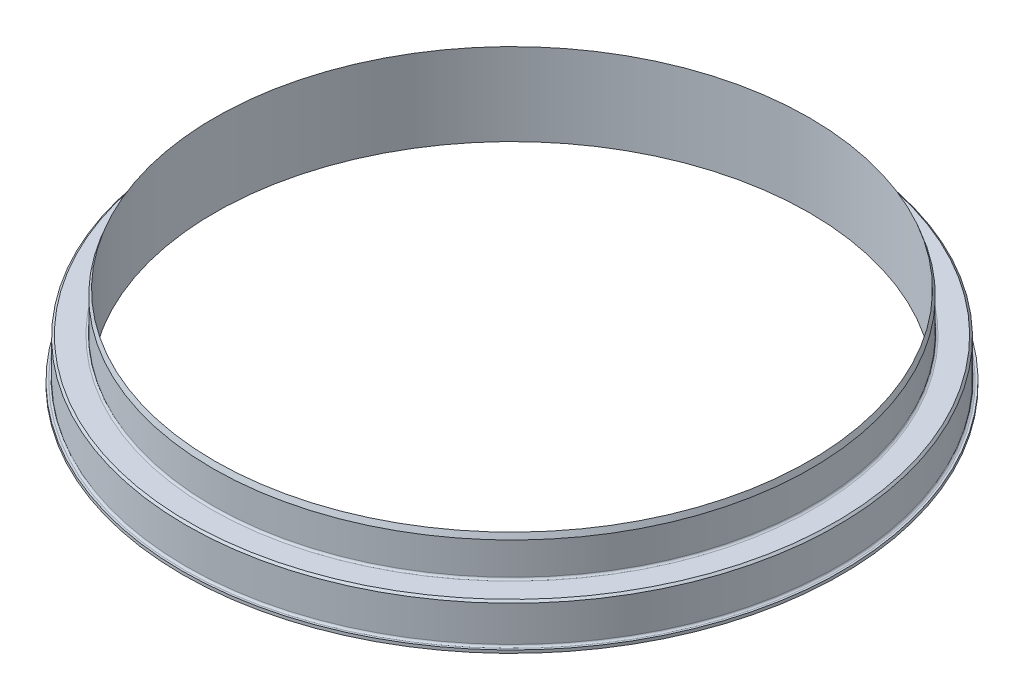
from build123d import *

# Parameters (mm, degrees)
FILLET1_R     = 0.508
CHAMFER1_SIZE = 0.508


with BuildPart() as part:
    # Sketch1 → Revolve1 (revolve)
    with BuildSketch(Plane.XY):
        Polygon((76.2, 21.082), (76.2, 0), (84.455, 0), (84.455, 0.762), (83.439, 0.762), (83.439, 10.922), (76.708, 10.922), (76.708, 19.686281471), align=None)
    revolve(axis=Axis((0, 28.738956579, 0), (0, -1, 0)))

    # Fillet1
    fillet1_edges = [part.edges().sort_by_distance(p)[0] for p in [
        (-83.439, 0.762, 0),
        (-76.708, 10.922, 0),
    ]]
    fillet(fillet1_edges, radius=FILLET1_R)

    # Chamfer1
    chamfer1_edges = [part.edges().sort_by_distance(p)[0] for p in [
        (-83.439, 10.922, 0),
    ]]
    chamfer(chamfer1_edges, length=CHAMFER1_SIZE)


solid = part.part
